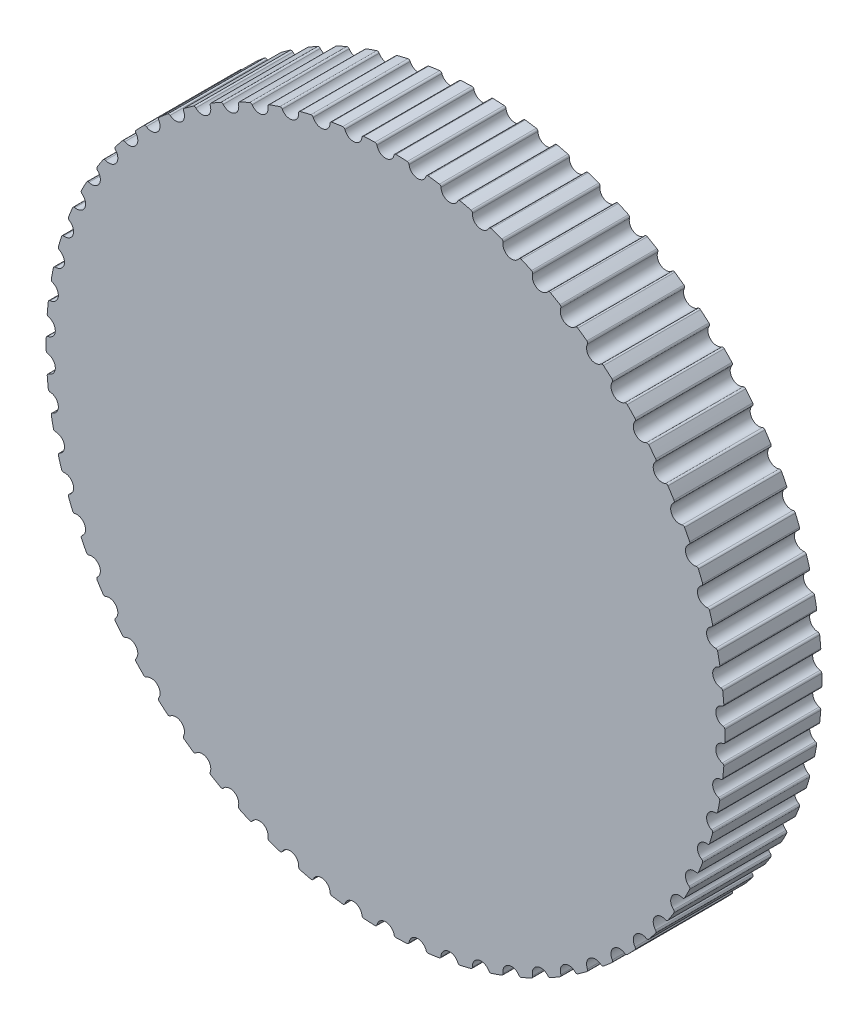
from build123d import *

# Parameters (mm, degrees)
BOSS_EXTRUDE1_DEPTH = 6


with BuildPart() as part:
    # Sketch1 → Boss-Extrude1 (new body)
    with BuildSketch(Plane.XY):
        with BuildLine():
            ThreePointArc((-0.528729205, 20.890248335), (-0.573745593, 20.963017021), (-0.655019148, 20.989782036))
            ThreePointArc((-0.655019148, 20.989782036), (-0.999220232, 20.976214123), (-1.34315246, 20.957002206))
            ThreePointArc((-1.34315246, 20.957002206), (-1.421513825, 20.922632842), (-1.459409272, 20.845914579))
            ThreePointArc((-1.459409272, 20.845914579), (-1.944846646, 20.367355536), (-2.512079428, 20.745396767))
            ThreePointArc((-2.512079428, 20.745396767), (-2.563809082, 20.813556871), (-2.647258801, 20.832475149))
            ThreePointArc((-2.647258801, 20.832475149), (-2.988611604, 20.78625028), (-3.32916027, 20.734432519))
            ThreePointArc((-3.32916027, 20.734432519), (-3.403899794, 20.692770061), (-3.434331113, 20.612796993))
            ThreePointArc((-3.434331113, 20.612796993), (-3.87208046, 20.090261146), (-4.472679872, 20.412671673))
            ThreePointArc((-4.472679872, 20.412671673), (-4.530654319, 20.475605926), (-4.615524468, 20.486506142))
            ThreePointArc((-4.615524468, 20.486506142), (-4.950937646, 20.408042935), (-5.28501869, 20.324088601))
            ThreePointArc((-5.28501869, 20.324088601), (-5.355459519, 20.27551035), (-5.37815112, 20.193006725))
            ThreePointArc((-5.37815112, 20.193006725), (-5.764248113, 19.63122624), (-6.392775034, 19.895086264))
            ThreePointArc((-6.392775034, 19.895086264), (-6.456469249, 19.952224724), (-6.541991231, 19.955008162))
            ThreePointArc((-6.541991231, 19.955008162), (-6.86842723, 19.845017193), (-7.193015163, 19.729686588))
            ThreePointArc((-7.193015163, 19.729686588), (-7.258519374, 19.674632477), (-7.273265757, 19.590345462))
            ThreePointArc((-7.273265757, 19.590345462), (-7.604213843, 18.99440791), (-8.254976235, 19.197327872))
            ThreePointArc((-8.254976235, 19.197327872), (-8.323813394, 19.248153085), (-8.409212708, 19.242794538))
            ThreePointArc((-8.409212708, 19.242794538), (-8.723715273, 19.102271902), (-9.035870576, 18.956609479))
            ThreePointArc((-9.035870576, 18.956609479), (-9.095844953, 18.895578086), (-9.102512573, 18.810270996))
            ThreePointArc((-9.102512573, 18.810270996), (-9.375314635, 18.185573279), (-10.042419093, 18.325715507))
            ThreePointArc((-10.042419093, 18.325715507), (-10.115775796, 18.369767191), (-10.200279052, 18.356315187))
            ThreePointArc((-10.200279052, 18.356315187), (-10.5, 18.186533479), (-10.796895746, 18.011858379))
            ThreePointArc((-10.796895746, 18.011858379), (-10.850797151, 17.945402414), (-10.849325625, 17.859847803))
            ThreePointArc((-10.849325625, 17.859847803), (-11.061511125, 17.212047282), (-11.738916248, 17.288142624))
            ThreePointArc((-11.738916248, 17.288142624), (-11.816128165, 17.325021841), (-11.89897009, 17.303598203))
            ThreePointArc((-11.89897009, 17.303598203), (-12.181195101, 17.106094993), (-12.460142556, 16.9039891))
            ThreePointArc((-12.460142556, 16.9039891), (-12.507482851, 16.832710398), (-12.497885505, 16.747683063))
            ThreePointArc((-12.497885505, 16.747683063), (-12.647532858, 16.082646318), (-13.32910396, 16.094005645))
            ThreePointArc((-13.32910396, 16.094005645), (-13.409471849, 16.12337841), (-13.489902213, 16.094177155))
            ThreePointArc((-13.489902213, 16.094177155), (-13.752075413, 15.870741061), (-14.010548386, 15.643034678))
            ThreePointArc((-14.010548386, 15.643034678), (-14.050898849, 15.567578751), (-14.033262598, 15.483848712))
            ThreePointArc((-14.033262598, 15.483848712), (-14.119016575, 14.80759842), (-14.798581243, 14.754118858))
            ThreePointArc((-14.798581243, 14.754118858), (-14.881377278, 14.775719168), (-14.958667692, 14.739004746))
            ThreePointArc((-14.958667692, 14.739004746), (-15.1984148, 14.491659241), (-15.434072519, 14.240414512))
            ThreePointArc((-15.434072519, 14.240414512), (-15.46706773, 14.1614647), (-15.441552292, 14.079790229))
            ThreePointArc((-15.441552292, 14.079790229), (-15.462636291, 13.398450617), (-16.134040283, 13.280616486))
            ThreePointArc((-16.134040283, 13.280616486), (-16.218514651, 13.294248724), (-16.291965159, 13.250353627))
            ThreePointArc((-16.291965159, 13.250353627), (-16.50711499, 12.981338711), (-16.717823303, 12.708830946))
            ThreePointArc((-16.717823303, 12.708830946), (-16.743164452, 12.627102231), (-16.710000898, 12.548222985))
            ThreePointArc((-16.710000898, 12.548222985), (-16.666223979, 11.86796437), (-17.323386955, 11.686842794))
            ThreePointArc((-17.323386955, 11.686842794), (-17.408774643, 11.692383506), (-17.477720068, 11.641705254))
            ThreePointArc((-17.477720068, 11.641705254), (-17.666324189, 11.353457167), (-17.850174889, 11.06215424))
            ThreePointArc((-17.850174889, 11.06215424), (-17.867632483, 10.978386769), (-17.827121147, 10.903017091))
            ThreePointArc((-17.827121147, 10.903017091), (-17.718879761, 10.23), (-18.355850352, 9.987231244))
            ThreePointArc((-18.355850352, 9.987231244), (-18.441378076, 9.984630252), (-18.505194037, 9.927627796))
            ThreePointArc((-18.505194037, 9.927627796), (-18.665544422, 9.622756956), (-18.820872528, 9.315296952))
            ThreePointArc((-18.820872528, 9.315296952), (-18.830288468, 9.230249337), (-18.782796227, 9.159071785))
            ThreePointArc((-18.782796227, 9.159071785), (-18.611070625, 8.499391166), (-19.222080326, 8.197173782))
            ThreePointArc((-19.222080326, 8.197173782), (-19.306973534, 8.18645464), (-19.365082103, 8.123644203))
            ThreePointArc((-19.365082103, 8.123644203), (-19.495726593, 7.804911569), (-19.62112543, 7.484078892))
            ThreePointArc((-19.62112543, 7.484078892), (-19.622414445, 7.398521337), (-19.568371396, 7.332180508))
            ThreePointArc((-19.568371396, 7.332180508), (-19.334716751, 6.691810529), (-19.914232164, 6.332881445))
            ThreePointArc((-19.914232164, 6.332881445), (-19.99772205, 6.314141227), (-20.049596987, 6.24609163))
            ThreePointArc((-20.049596987, 6.24609163), (-20.149352446, 5.916383694), (-20.243686382, 5.585083855))
            ThreePointArc((-20.243686382, 5.585083855), (-20.236836797, 5.499791182), (-20.176732363, 5.438887868))
            ThreePointArc((-20.176732363, 5.438887868), (-19.883264688, 4.823627821), (-20.426037632, 4.411237552))
            ThreePointArc((-20.426037632, 4.411237552), (-20.507368098, 4.384645973), (-20.552539616, 4.311973484))
            ThreePointArc((-20.552539616, 4.311973484), (-20.620502643, 3.974276132), (-20.682917375, 3.635509433))
            ThreePointArc((-20.682917375, 3.635509433), (-20.667991222, 3.551254067), (-20.602369717, 3.496339817))
            ThreePointArc((-20.602369717, 3.496339817), (-20.251746701, 2.911761591), (-20.75286174, 2.449644809))
            ThreePointArc((-20.75286174, 2.449644809), (-20.831296245, 2.415442687), (-20.869355264, 2.338805438))
            ThreePointArc((-20.869355264, 2.338805438), (-20.904910374, 1.996176909), (-20.934840666, 1.653011275))
            ThreePointArc((-20.934840666, 1.653011275), (-20.911973118, 1.570556245), (-20.841428821, 1.522128372))
            ThreePointArc((-20.841428821, 1.522128372), (-20.43682576, 0.973525998), (-20.891744718, 0.465867704))
            ThreePointArc((-20.891744718, 0.465867704), (-20.966572947, 0.424364778), (-20.997174798, 0.344456809))
            ThreePointArc((-20.997174798, 0.344456809), (-21, 0), (-20.997174798, -0.344456809))
            ThreePointArc((-20.997174798, -0.344456809), (-20.966572947, -0.424364778), (-20.891744718, -0.465867704))
            ThreePointArc((-20.891744718, -0.465867704), (-20.43682576, -0.973525998), (-20.841428821, -1.522128372))
            ThreePointArc((-20.841428821, -1.522128372), (-20.911973118, -1.570556245), (-20.934840666, -1.653011275))
            ThreePointArc((-20.934840666, -1.653011275), (-20.904910374, -1.996176909), (-20.869355264, -2.338805438))
            ThreePointArc((-20.869355264, -2.338805438), (-20.831296245, -2.415442687), (-20.75286174, -2.449644809))
            ThreePointArc((-20.75286174, -2.449644809), (-20.251746701, -2.911761591), (-20.602369717, -3.496339817))
            ThreePointArc((-20.602369717, -3.496339817), (-20.667991222, -3.551254067), (-20.682917375, -3.635509433))
            ThreePointArc((-20.682917375, -3.635509433), (-20.620502643, -3.974276132), (-20.552539616, -4.311973484))
            ThreePointArc((-20.552539616, -4.311973484), (-20.507368098, -4.384645973), (-20.426037632, -4.411237552))
            ThreePointArc((-20.426037632, -4.411237552), (-19.883264688, -4.823627821), (-20.176732363, -5.438887868))
            ThreePointArc((-20.176732363, -5.438887868), (-20.236836797, -5.499791182), (-20.243686382, -5.585083855))
            ThreePointArc((-20.243686382, -5.585083855), (-20.149352446, -5.916383694), (-20.049596987, -6.24609163))
            ThreePointArc((-20.049596987, -6.24609163), (-19.99772205, -6.314141227), (-19.914232164, -6.332881445))
            ThreePointArc((-19.914232164, -6.332881445), (-19.334716751, -6.691810529), (-19.568371396, -7.332180508))
            ThreePointArc((-19.568371396, -7.332180508), (-19.622414445, -7.398521337), (-19.62112543, -7.484078892))
            ThreePointArc((-19.62112543, -7.484078892), (-19.495726593, -7.804911569), (-19.365082103, -8.123644203))
            ThreePointArc((-19.365082103, -8.123644203), (-19.306973534, -8.18645464), (-19.222080326, -8.197173782))
            ThreePointArc((-19.222080326, -8.197173782), (-18.611070625, -8.499391166), (-18.782796227, -9.159071785))
            ThreePointArc((-18.782796227, -9.159071785), (-18.830288468, -9.230249337), (-18.820872528, -9.315296952))
            ThreePointArc((-18.820872528, -9.315296952), (-18.665544422, -9.622756956), (-18.505194037, -9.927627796))
            ThreePointArc((-18.505194037, -9.927627796), (-18.441378076, -9.984630252), (-18.355850352, -9.987231244))
            ThreePointArc((-18.355850352, -9.987231244), (-17.718879761, -10.23), (-17.827121147, -10.903017091))
            ThreePointArc((-17.827121147, -10.903017091), (-17.867632483, -10.978386769), (-17.850174889, -11.06215424))
            ThreePointArc((-17.850174889, -11.06215424), (-17.666324189, -11.353457167), (-17.477720068, -11.641705254))
            ThreePointArc((-17.477720068, -11.641705254), (-17.408774643, -11.692383506), (-17.323386955, -11.686842794))
            ThreePointArc((-17.323386955, -11.686842794), (-16.666223979, -11.86796437), (-16.710000898, -12.548222985))
            ThreePointArc((-16.710000898, -12.548222985), (-16.743164452, -12.627102231), (-16.717823303, -12.708830946))
            ThreePointArc((-16.717823303, -12.708830946), (-16.50711499, -12.981338711), (-16.291965159, -13.250353627))
            ThreePointArc((-16.291965159, -13.250353627), (-16.218514651, -13.294248724), (-16.134040283, -13.280616486))
            ThreePointArc((-16.134040283, -13.280616486), (-15.462636291, -13.398450617), (-15.441552292, -14.079790229))
            ThreePointArc((-15.441552292, -14.079790229), (-15.46706773, -14.1614647), (-15.434072519, -14.240414512))
            ThreePointArc((-15.434072519, -14.240414512), (-15.1984148, -14.491659241), (-14.958667692, -14.739004746))
            ThreePointArc((-14.958667692, -14.739004746), (-14.881377278, -14.775719168), (-14.798581243, -14.754118858))
            ThreePointArc((-14.798581243, -14.754118858), (-14.119016575, -14.80759842), (-14.033262598, -15.483848712))
            ThreePointArc((-14.033262598, -15.483848712), (-14.050898849, -15.567578751), (-14.010548386, -15.643034678))
            ThreePointArc((-14.010548386, -15.643034678), (-13.752075413, -15.870741061), (-13.489902213, -16.094177155))
            ThreePointArc((-13.489902213, -16.094177155), (-13.409471849, -16.12337841), (-13.32910396, -16.094005645))
            ThreePointArc((-13.32910396, -16.094005645), (-12.647532858, -16.082646318), (-12.497885505, -16.747683063))
            ThreePointArc((-12.497885505, -16.747683063), (-12.507482851, -16.832710398), (-12.460142556, -16.9039891))
            ThreePointArc((-12.460142556, -16.9039891), (-12.181195101, -17.106094993), (-11.89897009, -17.303598203))
            ThreePointArc((-11.89897009, -17.303598203), (-11.816128165, -17.325021841), (-11.738916248, -17.288142624))
            ThreePointArc((-11.738916248, -17.288142624), (-11.061511125, -17.212047282), (-10.849325625, -17.859847803))
            ThreePointArc((-10.849325625, -17.859847803), (-10.850797151, -17.945402414), (-10.796895746, -18.011858379))
            ThreePointArc((-10.796895746, -18.011858379), (-10.5, -18.186533479), (-10.200279052, -18.356315187))
            ThreePointArc((-10.200279052, -18.356315187), (-10.115775796, -18.369767191), (-10.042419093, -18.325715507))
            ThreePointArc((-10.042419093, -18.325715507), (-9.375314635, -18.185573279), (-9.102512573, -18.810270996))
            ThreePointArc((-9.102512573, -18.810270996), (-9.095844953, -18.895578086), (-9.035870576, -18.956609479))
            ThreePointArc((-9.035870576, -18.956609479), (-8.723715273, -19.102271902), (-8.409212708, -19.242794538))
            ThreePointArc((-8.409212708, -19.242794538), (-8.323813394, -19.248153085), (-8.254976235, -19.197327872))
            ThreePointArc((-8.254976235, -19.197327872), (-7.604213843, -18.99440791), (-7.273265757, -19.590345462))
            ThreePointArc((-7.273265757, -19.590345462), (-7.258519374, -19.674632477), (-7.193015163, -19.729686588))
            ThreePointArc((-7.193015163, -19.729686588), (-6.86842723, -19.845017193), (-6.541991231, -19.955008162))
            ThreePointArc((-6.541991231, -19.955008162), (-6.456469249, -19.952224724), (-6.392775034, -19.895086264))
            ThreePointArc((-6.392775034, -19.895086264), (-5.764248113, -19.63122624), (-5.37815112, -20.193006725))
            ThreePointArc((-5.37815112, -20.193006725), (-5.355459519, -20.27551035), (-5.28501869, -20.324088601))
            ThreePointArc((-5.28501869, -20.324088601), (-4.950937646, -20.408042935), (-4.615524468, -20.486506142))
            ThreePointArc((-4.615524468, -20.486506142), (-4.530654319, -20.475605926), (-4.472679872, -20.412671673))
            ThreePointArc((-4.472679872, -20.412671673), (-3.87208046, -20.090261146), (-3.434331113, -20.612796993))
            ThreePointArc((-3.434331113, -20.612796993), (-3.403899794, -20.692770061), (-3.32916027, -20.734432519))
            ThreePointArc((-3.32916027, -20.734432519), (-2.988611604, -20.78625028), (-2.647258801, -20.832475149))
            ThreePointArc((-2.647258801, -20.832475149), (-2.563809082, -20.813556871), (-2.512079428, -20.745396767))
            ThreePointArc((-2.512079428, -20.745396767), (-1.944846646, -20.367355536), (-1.459409272, -20.845914579))
            ThreePointArc((-1.459409272, -20.845914579), (-1.421513825, -20.922632842), (-1.34315246, -20.957002206))
            ThreePointArc((-1.34315246, -20.957002206), (-0.999220232, -20.976214123), (-0.655019148, -20.989782036))
            ThreePointArc((-0.655019148, -20.989782036), (-0.573745593, -20.963017021), (-0.528729205, -20.890248335))
            ThreePointArc((-0.528729205, -20.890248335), (0, -20.46), (0.528729205, -20.890248335))
            ThreePointArc((0.528729205, -20.890248335), (0.573745593, -20.963017021), (0.655019148, -20.989782036))
            ThreePointArc((0.655019148, -20.989782036), (0.999220232, -20.976214123), (1.34315246, -20.957002206))
            ThreePointArc((1.34315246, -20.957002206), (1.421513825, -20.922632842), (1.459409272, -20.845914579))
            ThreePointArc((1.459409272, -20.845914579), (1.944846646, -20.367355536), (2.512079428, -20.745396767))
            ThreePointArc((2.512079428, -20.745396767), (2.563809082, -20.813556871), (2.647258801, -20.832475149))
            ThreePointArc((2.647258801, -20.832475149), (2.988611604, -20.78625028), (3.32916027, -20.734432519))
            ThreePointArc((3.32916027, -20.734432519), (3.403899794, -20.692770061), (3.434331113, -20.612796993))
            ThreePointArc((3.434331113, -20.612796993), (3.87208046, -20.090261146), (4.472679872, -20.412671673))
            ThreePointArc((4.472679872, -20.412671673), (4.530654319, -20.475605926), (4.615524468, -20.486506142))
            ThreePointArc((4.615524468, -20.486506142), (4.950937646, -20.408042935), (5.28501869, -20.324088601))
            ThreePointArc((5.28501869, -20.324088601), (5.355459519, -20.27551035), (5.37815112, -20.193006725))
            ThreePointArc((5.37815112, -20.193006725), (5.764248113, -19.63122624), (6.392775034, -19.895086264))
            ThreePointArc((6.392775034, -19.895086264), (6.456469249, -19.952224724), (6.541991231, -19.955008162))
            ThreePointArc((6.541991231, -19.955008162), (6.86842723, -19.845017193), (7.193015163, -19.729686588))
            ThreePointArc((7.193015163, -19.729686588), (7.258519374, -19.674632477), (7.273265757, -19.590345462))
            ThreePointArc((7.273265757, -19.590345462), (7.604213843, -18.99440791), (8.254976235, -19.197327872))
            ThreePointArc((8.254976235, -19.197327872), (8.323813394, -19.248153085), (8.409212708, -19.242794538))
            ThreePointArc((8.409212708, -19.242794538), (8.723715273, -19.102271902), (9.035870576, -18.956609479))
            ThreePointArc((9.035870576, -18.956609479), (9.095844953, -18.895578086), (9.102512573, -18.810270996))
            ThreePointArc((9.102512573, -18.810270996), (9.375314635, -18.185573279), (10.042419093, -18.325715507))
            ThreePointArc((10.042419093, -18.325715507), (10.115775796, -18.369767191), (10.200279052, -18.356315187))
            ThreePointArc((10.200279052, -18.356315187), (10.5, -18.186533479), (10.796895746, -18.011858379))
            ThreePointArc((10.796895746, -18.011858379), (10.850797151, -17.945402414), (10.849325625, -17.859847803))
            ThreePointArc((10.849325625, -17.859847803), (11.061511125, -17.212047282), (11.738916248, -17.288142624))
            ThreePointArc((11.738916248, -17.288142624), (11.816128165, -17.325021841), (11.89897009, -17.303598203))
            ThreePointArc((11.89897009, -17.303598203), (12.181195101, -17.106094993), (12.460142556, -16.9039891))
            ThreePointArc((12.460142556, -16.9039891), (12.507482851, -16.832710398), (12.497885505, -16.747683063))
            ThreePointArc((12.497885505, -16.747683063), (12.647532858, -16.082646318), (13.32910396, -16.094005645))
            ThreePointArc((13.32910396, -16.094005645), (13.409471849, -16.12337841), (13.489902213, -16.094177155))
            ThreePointArc((13.489902213, -16.094177155), (13.752075413, -15.870741061), (14.010548386, -15.643034678))
            ThreePointArc((14.010548386, -15.643034678), (14.050898849, -15.567578751), (14.033262598, -15.483848712))
            ThreePointArc((14.033262598, -15.483848712), (14.119016575, -14.80759842), (14.798581243, -14.754118858))
            ThreePointArc((14.798581243, -14.754118858), (14.881377278, -14.775719168), (14.958667692, -14.739004746))
            ThreePointArc((14.958667692, -14.739004746), (15.1984148, -14.491659241), (15.434072519, -14.240414512))
            ThreePointArc((15.434072519, -14.240414512), (15.46706773, -14.1614647), (15.441552292, -14.079790229))
            ThreePointArc((15.441552292, -14.079790229), (15.462636291, -13.398450617), (16.134040283, -13.280616486))
            ThreePointArc((16.134040283, -13.280616486), (16.218514651, -13.294248724), (16.291965159, -13.250353627))
            ThreePointArc((16.291965159, -13.250353627), (16.50711499, -12.981338711), (16.717823303, -12.708830946))
            ThreePointArc((16.717823303, -12.708830946), (16.743164452, -12.627102231), (16.710000898, -12.548222985))
            ThreePointArc((16.710000898, -12.548222985), (16.666223979, -11.86796437), (17.323386955, -11.686842794))
            ThreePointArc((17.323386955, -11.686842794), (17.408774643, -11.692383506), (17.477720068, -11.641705254))
            ThreePointArc((17.477720068, -11.641705254), (17.666324189, -11.353457167), (17.850174889, -11.06215424))
            ThreePointArc((17.850174889, -11.06215424), (17.867632483, -10.978386769), (17.827121147, -10.903017091))
            ThreePointArc((17.827121147, -10.903017091), (17.718879761, -10.23), (18.355850352, -9.987231244))
            ThreePointArc((18.355850352, -9.987231244), (18.441378076, -9.984630252), (18.505194037, -9.927627796))
            ThreePointArc((18.505194037, -9.927627796), (18.665544422, -9.622756956), (18.820872528, -9.315296952))
            ThreePointArc((18.820872528, -9.315296952), (18.830288468, -9.230249337), (18.782796227, -9.159071785))
            ThreePointArc((18.782796227, -9.159071785), (18.611070625, -8.499391166), (19.222080326, -8.197173782))
            ThreePointArc((19.222080326, -8.197173782), (19.306973534, -8.18645464), (19.365082103, -8.123644203))
            ThreePointArc((19.365082103, -8.123644203), (19.495726593, -7.804911569), (19.62112543, -7.484078892))
            ThreePointArc((19.62112543, -7.484078892), (19.622414445, -7.398521337), (19.568371396, -7.332180508))
            ThreePointArc((19.568371396, -7.332180508), (19.334716751, -6.691810529), (19.914232164, -6.332881445))
            ThreePointArc((19.914232164, -6.332881445), (19.99772205, -6.314141227), (20.049596987, -6.24609163))
            ThreePointArc((20.049596987, -6.24609163), (20.149352446, -5.916383694), (20.243686382, -5.585083855))
            ThreePointArc((20.243686382, -5.585083855), (20.236836797, -5.499791182), (20.176732363, -5.438887868))
            ThreePointArc((20.176732363, -5.438887868), (19.883264688, -4.823627821), (20.426037632, -4.411237552))
            ThreePointArc((20.426037632, -4.411237552), (20.507368098, -4.384645973), (20.552539616, -4.311973484))
            ThreePointArc((20.552539616, -4.311973484), (20.620502643, -3.974276132), (20.682917375, -3.635509433))
            ThreePointArc((20.682917375, -3.635509433), (20.667991222, -3.551254067), (20.602369717, -3.496339817))
            ThreePointArc((20.602369717, -3.496339817), (20.251746701, -2.911761591), (20.75286174, -2.449644809))
            ThreePointArc((20.75286174, -2.449644809), (20.831296245, -2.415442687), (20.869355264, -2.338805438))
            ThreePointArc((20.869355264, -2.338805438), (20.904910374, -1.996176909), (20.934840666, -1.653011275))
            ThreePointArc((20.934840666, -1.653011275), (20.911973118, -1.570556245), (20.841428821, -1.522128372))
            ThreePointArc((20.841428821, -1.522128372), (20.43682576, -0.973525998), (20.891744718, -0.465867704))
            ThreePointArc((20.891744718, -0.465867704), (20.966572947, -0.424364778), (20.997174798, -0.344456809))
            ThreePointArc((20.997174798, -0.344456809), (21, 0), (20.997174798, 0.344456809))
            ThreePointArc((20.997174798, 0.344456809), (20.966572947, 0.424364778), (20.891744718, 0.465867704))
            ThreePointArc((20.891744718, 0.465867704), (20.43682576, 0.973525998), (20.841428821, 1.522128372))
            ThreePointArc((20.841428821, 1.522128372), (20.911973118, 1.570556245), (20.934840666, 1.653011275))
            ThreePointArc((20.934840666, 1.653011275), (20.904910374, 1.996176909), (20.869355264, 2.338805438))
            ThreePointArc((20.869355264, 2.338805438), (20.831296245, 2.415442687), (20.75286174, 2.449644809))
            ThreePointArc((20.75286174, 2.449644809), (20.251746701, 2.911761591), (20.602369717, 3.496339817))
            ThreePointArc((20.602369717, 3.496339817), (20.667991222, 3.551254067), (20.682917375, 3.635509433))
            ThreePointArc((20.682917375, 3.635509433), (20.620502643, 3.974276132), (20.552539616, 4.311973484))
            ThreePointArc((20.552539616, 4.311973484), (20.507368098, 4.384645973), (20.426037632, 4.411237552))
            ThreePointArc((20.426037632, 4.411237552), (19.883264688, 4.823627821), (20.176732363, 5.438887868))
            ThreePointArc((20.176732363, 5.438887868), (20.236836797, 5.499791182), (20.243686382, 5.585083855))
            ThreePointArc((20.243686382, 5.585083855), (20.149352446, 5.916383694), (20.049596987, 6.24609163))
            ThreePointArc((20.049596987, 6.24609163), (19.99772205, 6.314141227), (19.914232164, 6.332881445))
            ThreePointArc((19.914232164, 6.332881445), (19.334716751, 6.691810529), (19.568371396, 7.332180508))
            ThreePointArc((19.568371396, 7.332180508), (19.622414445, 7.398521337), (19.62112543, 7.484078892))
            ThreePointArc((19.62112543, 7.484078892), (19.495726593, 7.804911569), (19.365082103, 8.123644203))
            ThreePointArc((19.365082103, 8.123644203), (19.306973534, 8.18645464), (19.222080326, 8.197173782))
            ThreePointArc((19.222080326, 8.197173782), (18.611070625, 8.499391166), (18.782796227, 9.159071785))
            ThreePointArc((18.782796227, 9.159071785), (18.830288468, 9.230249337), (18.820872528, 9.315296952))
            ThreePointArc((18.820872528, 9.315296952), (18.665544422, 9.622756956), (18.505194037, 9.927627796))
            ThreePointArc((18.505194037, 9.927627796), (18.441378076, 9.984630252), (18.355850352, 9.987231244))
            ThreePointArc((18.355850352, 9.987231244), (17.718879761, 10.23), (17.827121147, 10.903017091))
            ThreePointArc((17.827121147, 10.903017091), (17.867632483, 10.978386769), (17.850174889, 11.06215424))
            ThreePointArc((17.850174889, 11.06215424), (17.666324189, 11.353457167), (17.477720068, 11.641705254))
            ThreePointArc((17.477720068, 11.641705254), (17.408774643, 11.692383506), (17.323386955, 11.686842794))
            ThreePointArc((17.323386955, 11.686842794), (16.666223979, 11.86796437), (16.710000898, 12.548222985))
            ThreePointArc((16.710000898, 12.548222985), (16.743164452, 12.627102231), (16.717823303, 12.708830946))
            ThreePointArc((16.717823303, 12.708830946), (16.50711499, 12.981338711), (16.291965159, 13.250353627))
            ThreePointArc((16.291965159, 13.250353627), (16.218514651, 13.294248724), (16.134040283, 13.280616486))
            ThreePointArc((16.134040283, 13.280616486), (15.462636291, 13.398450617), (15.441552292, 14.079790229))
            ThreePointArc((15.441552292, 14.079790229), (15.46706773, 14.1614647), (15.434072519, 14.240414512))
            ThreePointArc((15.434072519, 14.240414512), (15.1984148, 14.491659241), (14.958667692, 14.739004746))
            ThreePointArc((14.958667692, 14.739004746), (14.881377278, 14.775719168), (14.798581243, 14.754118858))
            ThreePointArc((14.798581243, 14.754118858), (14.119016575, 14.80759842), (14.033262598, 15.483848712))
            ThreePointArc((14.033262598, 15.483848712), (14.050898849, 15.567578751), (14.010548386, 15.643034678))
            ThreePointArc((14.010548386, 15.643034678), (13.752075413, 15.870741061), (13.489902213, 16.094177155))
            ThreePointArc((13.489902213, 16.094177155), (13.409471849, 16.12337841), (13.32910396, 16.094005645))
            ThreePointArc((13.32910396, 16.094005645), (12.647532858, 16.082646318), (12.497885505, 16.747683063))
            ThreePointArc((12.497885505, 16.747683063), (12.507482851, 16.832710398), (12.460142556, 16.9039891))
            ThreePointArc((12.460142556, 16.9039891), (12.181195101, 17.106094993), (11.89897009, 17.303598203))
            ThreePointArc((11.89897009, 17.303598203), (11.816128165, 17.325021841), (11.738916248, 17.288142624))
            ThreePointArc((11.738916248, 17.288142624), (11.061511125, 17.212047282), (10.849325625, 17.859847803))
            ThreePointArc((10.849325625, 17.859847803), (10.850797151, 17.945402414), (10.796895746, 18.011858379))
            ThreePointArc((10.796895746, 18.011858379), (10.5, 18.186533479), (10.200279052, 18.356315187))
            ThreePointArc((10.200279052, 18.356315187), (10.115775796, 18.369767191), (10.042419093, 18.325715507))
            ThreePointArc((10.042419093, 18.325715507), (9.375314635, 18.185573279), (9.102512573, 18.810270996))
            ThreePointArc((9.102512573, 18.810270996), (9.095844953, 18.895578086), (9.035870576, 18.956609479))
            ThreePointArc((9.035870576, 18.956609479), (8.723715273, 19.102271902), (8.409212708, 19.242794538))
            ThreePointArc((8.409212708, 19.242794538), (8.323813394, 19.248153085), (8.254976235, 19.197327872))
            ThreePointArc((8.254976235, 19.197327872), (7.604213843, 18.99440791), (7.273265757, 19.590345462))
            ThreePointArc((7.273265757, 19.590345462), (7.258519374, 19.674632477), (7.193015163, 19.729686588))
            ThreePointArc((7.193015163, 19.729686588), (6.86842723, 19.845017193), (6.541991231, 19.955008162))
            ThreePointArc((6.541991231, 19.955008162), (6.456469249, 19.952224724), (6.392775034, 19.895086264))
            ThreePointArc((6.392775034, 19.895086264), (5.764248113, 19.63122624), (5.37815112, 20.193006725))
            ThreePointArc((5.37815112, 20.193006725), (5.355459519, 20.27551035), (5.28501869, 20.324088601))
            ThreePointArc((5.28501869, 20.324088601), (4.950937646, 20.408042935), (4.615524468, 20.486506142))
            ThreePointArc((4.615524468, 20.486506142), (4.530654319, 20.475605926), (4.472679872, 20.412671673))
            ThreePointArc((4.472679872, 20.412671673), (3.87208046, 20.090261146), (3.434331113, 20.612796993))
            ThreePointArc((3.434331113, 20.612796993), (3.403899794, 20.692770061), (3.32916027, 20.734432519))
            ThreePointArc((3.32916027, 20.734432519), (2.988611604, 20.78625028), (2.647258801, 20.832475149))
            ThreePointArc((2.647258801, 20.832475149), (2.563809082, 20.813556871), (2.512079428, 20.745396767))
            ThreePointArc((2.512079428, 20.745396767), (1.944846646, 20.367355536), (1.459409272, 20.845914579))
            ThreePointArc((1.459409272, 20.845914579), (1.421513825, 20.922632842), (1.34315246, 20.957002206))
            ThreePointArc((1.34315246, 20.957002206), (0.999220232, 20.976214123), (0.655019148, 20.989782036))
            ThreePointArc((0.655019148, 20.989782036), (0.573745593, 20.963017021), (0.528729205, 20.890248335))
            ThreePointArc((0.528729205, 20.890248335), (0, 20.46), (-0.528729205, 20.890248335))
        make_face()
    extrude(amount=BOSS_EXTRUDE1_DEPTH)


solid = part.part
